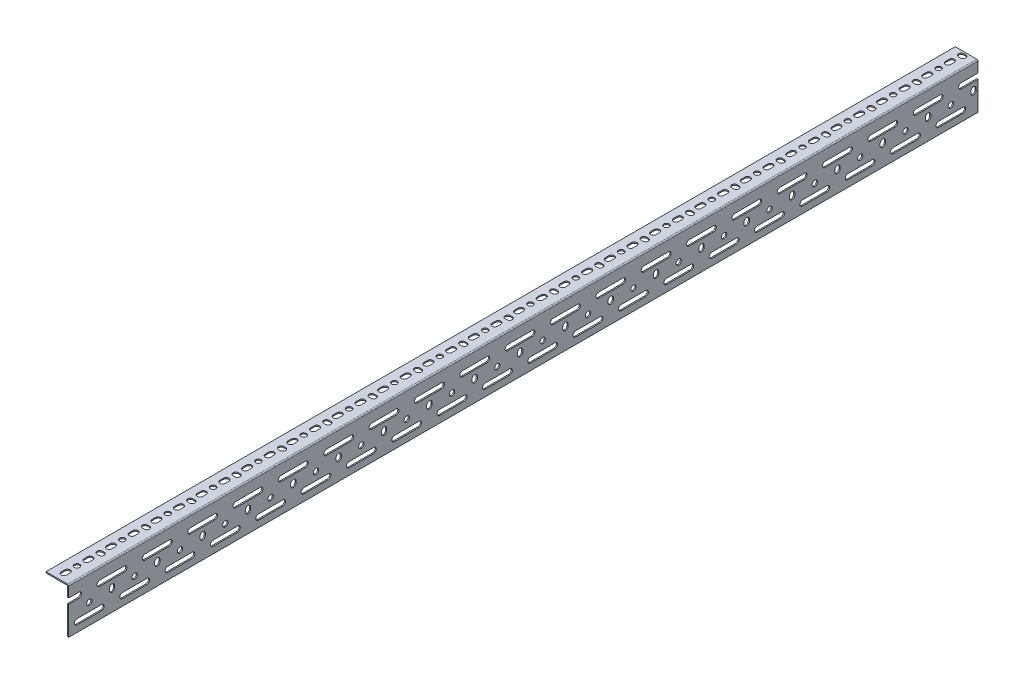
from build123d import *

# Parameters (mm, degrees)
STRUCTURAL_MEMBER1_DEPTH      = 1524
SLOT_1_5_DEPTH                = 1527.37939255
SKETCH13_R                    = 4.5
HOLE_1_5_DEPTH                = 1527.37939255
VERTICAL_SLOT_1_5_DEPTH       = 1527.37939255
LONG_SLOT_2_5_DEPTH           = 1527.37939255
SKETCH16_R                    = 4.5
HOLE_2_5_DEPTH                = 1527.37939255
VERTICAL_SLOT_2_5_DEPTH       = 1527.37939255
LONG_SLOT_2_5_2_DEPTH         = 1527.37939255
SHORT_SLOT_PATTERN_1_5_COUNT  = 40
SHORT_SLOT_PATTERN_1_5_PITCH  = 38
HOLE_PATTERN_COUNT            = 20
HOLE_PATTERN_PITCH            = 76
VERT_SLOT_PATTERN_COUNT       = 20
VERT_SLOT_PATTERN_PITCH       = 76
LONG_SLOT_PATTERN_COUNT       = 20
LONG_SLOT_PATTERN_PITCH       = 76
LONG_SLOT_PATTERN_2_COUNT     = 20
LONG_SLOT_PATTERN_2_PITCH     = 76
LONG_SLOT_PATTERN_2_COL_COUNT = 2
LONG_SLOT_PATTERN_2_COL_PITCH = 76


with BuildPart() as part:
    # Sketch110 → Structural Member1 (new body)
    with BuildSketch(Plane(origin=(0, 0, 0), x_dir=(-1, 0, 0), z_dir=(0, 0, 1))):
        with BuildLine():
            Line((0, 2), (0, 76.2))
            Line((0, 76.2), (1, 76.2))
            ThreePointArc((1, 76.2), (1.707106781, 75.907106781), (2, 75.2))
            Line((2, 75.2), (2, 4))
            ThreePointArc((2, 4), (2.585786438, 2.585786438), (4, 2))
            Line((4, 2), (37.1, 2))
            ThreePointArc((37.1, 2), (37.807106781, 1.707106781), (38.1, 1))
            Line((38.1, 1), (38.1, 0))
            Line((38.1, 0), (2, 0))
            ThreePointArc((2, 0), (0.585786438, 0.585786438), (0, 2))
        make_face()
    extrude(amount=-STRUCTURAL_MEMBER1_DEPTH)

    # Sketch12 → Slot 1.5 (cut, through all)
    with BuildSketch(Plane(origin=(0, 0, 0), x_dir=(1, 0, 0), z_dir=(0, 1, 0))):
        with BuildLine():
            Line((-25.1, 12.5), (-25.1, 18.5))
            ThreePointArc((-25.1, 18.5), (-20.6, 23), (-16.1, 18.5))
            Line((-16.1, 18.5), (-16.1, 12.5))
            ThreePointArc((-16.1, 12.5), (-20.6, 8), (-25.1, 12.5))
        make_face()
    slot_1_5 = extrude(amount=-SLOT_1_5_DEPTH, mode=Mode.SUBTRACT)

    # Sketch13 → Hole 1.5 (cut, through all)
    with BuildSketch(Plane(origin=(0, 0, 0), x_dir=(1, 0, 0), z_dir=(0, 1, 0))):
        with Locations(Location((-20.6, 34.5, 0), (0, 0, 180))):
            Circle(SKETCH13_R)
    hole_1_5 = extrude(amount=-HOLE_1_5_DEPTH, mode=Mode.SUBTRACT)

    # Sketch18 → Vertical Slot 1.5 (cut, through all)
    with BuildSketch(Plane(origin=(0, 0, 0), x_dir=(1, 0, 0), z_dir=(0, 1, 0))):
        with BuildLine():
            Line((-20.6, 77), (-17.6, 77))
            ThreePointArc((-17.6, 77), (-13.1, 72.5), (-17.6, 68))
            Line((-17.6, 68), (-20.6, 68))
            ThreePointArc((-20.6, 68), (-25.1, 72.5), (-20.6, 77))
        make_face()
    vertical_slot_1_5 = extrude(amount=-VERTICAL_SLOT_1_5_DEPTH, mode=Mode.SUBTRACT)

    # Sketch14 → Long Slot 2.5 (cut, through all)
    with BuildSketch(Plane(origin=(0, 0, 0), x_dir=(0, 0, -1), z_dir=(1, 0, 0))):
        with BuildLine():
            Line((14, -56.2), (55, -56.2))
            ThreePointArc((55, -56.2), (59.5, -60.7), (55, -65.2))
            Line((55, -65.2), (14, -65.2))
            ThreePointArc((14, -65.2), (9.5, -60.7), (14, -56.2))
        make_face()
    long_slot_2_5 = extrude(amount=-LONG_SLOT_2_5_DEPTH, mode=Mode.SUBTRACT)

    # Sketch16 → Hole 2.5 (cut, through all)
    with BuildSketch(Plane(origin=(0, 0, 0), x_dir=(0, 0, -1), z_dir=(1, 0, 0))):
        with Locations((34.5, -42.7)):
            Circle(SKETCH16_R)
    hole_2_5 = extrude(amount=-HOLE_2_5_DEPTH, mode=Mode.SUBTRACT)

    # Sketch17 → Vertical Slot 2.5 (cut, through all)
    with BuildSketch(Plane(origin=(0, 0, 0), x_dir=(0, 0, -1), z_dir=(1, 0, 0))):
        with BuildLine():
            Line((77, -39.7), (77, -42.7))
            ThreePointArc((77, -42.7), (72.5, -47.2), (68, -42.7))
            Line((68, -42.7), (68, -39.7))
            ThreePointArc((68, -39.7), (72.5, -35.2), (77, -39.7))
        make_face()
    vertical_slot_2_5 = extrude(amount=-VERTICAL_SLOT_2_5_DEPTH, mode=Mode.SUBTRACT)

    # Sketch112 → Long Slot 2.5 _2 (cut, through all)
    with BuildSketch(Plane(origin=(0, 0, 0), x_dir=(0, 0, -1), z_dir=(1, 0, 0))):
        with BuildLine():
            Line((52, -19.2), (93, -19.2))
            ThreePointArc((93, -19.2), (97.5, -23.7), (93, -28.2))
            Line((93, -28.2), (52, -28.2))
            ThreePointArc((52, -28.2), (47.5, -23.7), (52, -19.2))
        make_face()
    long_slot_2_5_2 = extrude(amount=-LONG_SLOT_2_5_2_DEPTH, mode=Mode.SUBTRACT)

    # Short Slot pattern 1.5: Slot 1.5 ×40
    with Locations(*[(0, 0, -i * SHORT_SLOT_PATTERN_1_5_PITCH) for i in range(1, SHORT_SLOT_PATTERN_1_5_COUNT)]):
        add(slot_1_5, mode=Mode.SUBTRACT)

    # Hole pattern: Hole 1.5, Hole 2.5 ×20
    with Locations(*[(0, 0, -i * HOLE_PATTERN_PITCH) for i in range(1, HOLE_PATTERN_COUNT)]):
        add(hole_1_5, mode=Mode.SUBTRACT)
        add(hole_2_5, mode=Mode.SUBTRACT)

    # Vert Slot Pattern: Vertical Slot 1.5, Vertical Slot 2.5 ×20
    with Locations(*[(0, 0, -i * VERT_SLOT_PATTERN_PITCH) for i in range(1, VERT_SLOT_PATTERN_COUNT)]):
        add(vertical_slot_1_5, mode=Mode.SUBTRACT)
        add(vertical_slot_2_5, mode=Mode.SUBTRACT)

    # Long Slot pattern: Long Slot 2.5 ×20
    with Locations(*[(0, 0, -i * LONG_SLOT_PATTERN_PITCH) for i in range(1, LONG_SLOT_PATTERN_COUNT)]):
        add(long_slot_2_5, mode=Mode.SUBTRACT)

    # Long Slot Pattern _2: Long Slot 2.5 _2 ×20
    with Locations(*[(0, 0, -i * LONG_SLOT_PATTERN_2_PITCH) for i in range(1, LONG_SLOT_PATTERN_2_COUNT)]):
        add(long_slot_2_5_2, mode=Mode.SUBTRACT)

    # Long Slot Pattern _2 col: Long Slot 2.5 _2 ×2
    with Locations(*[(0, 0, i * LONG_SLOT_PATTERN_2_COL_PITCH) for i in range(1, LONG_SLOT_PATTERN_2_COL_COUNT)]):
        add(long_slot_2_5_2, mode=Mode.SUBTRACT)


solid = part.part
